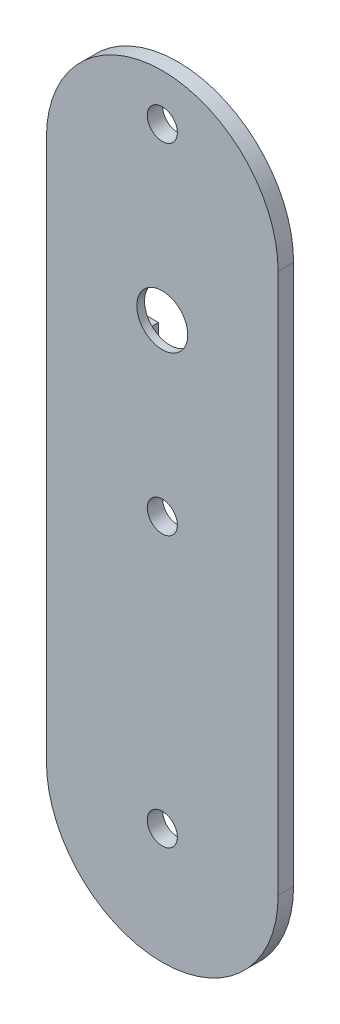
from build123d import *

# Parameters (mm, degrees)
BOSS_EXTRU_1_DEPTH      = 2
D_GAGEMENT_M3_51_D      = 3.9
ENL_V_MAT_EXTRU_3_DEPTH = 1
D_GAGEMENT_M3_52_D      = 3.9
D_GAGEMENT_M61_D        = 6.6


with BuildPart() as part:
    # Esquisse1 → Boss.-Extru.1 (new body)
    with BuildSketch(Plane.XY):
        with BuildLine():
            ThreePointArc((30, 0), (15, -15), (0, 0))
            Line((0, 0), (0, 70))
            ThreePointArc((0, 70), (15, 85), (30, 70))
            Line((30, 70), (30, 0))
        make_face()
    extrude(amount=BOSS_EXTRU_1_DEPTH)

    # Dégagement M3.51 (through all)
    with Locations(Plane(origin=(0, 0, 0), x_dir=(-1, 0, 0), z_dir=(0, 0, -1))):
        with Locations((-15, 79), (-15, 35)):
            Hole(D_GAGEMENT_M3_51_D / 2)

    # Esquisse5 → Enlèv. mat.-Extru.3 (cut)
    with BuildSketch(Plane(origin=(0, 0, 0), x_dir=(-1, 0, 0), z_dir=(0, 0, -1))):
        Polygon((-12.5, 54.5), (-2.5, 54.5), (-2.5, 59.5), (-12.5, 59.5), (-12.5, 69.5), (-17.5, 69.5), (-17.5, 59.5), (-27.5, 59.5), (-27.5, 54.5), (-17.5, 54.5), (-17.5, 44.5), (-12.5, 44.5), align=None)
    extrude(amount=-ENL_V_MAT_EXTRU_3_DEPTH, mode=Mode.SUBTRACT)

    # Dégagement M3.52 (through all)
    with Locations(Plane(origin=(0, 0, 0), x_dir=(-1, 0, 0), z_dir=(0, 0, -1))):
        with Locations((-15, 0)):
            Hole(D_GAGEMENT_M3_52_D / 2)

    # Dégagement M61 (through all)
    with Locations(Plane(origin=(0, 0, 0), x_dir=(-1, 0, 0), z_dir=(0, 0, -1))):
        with Locations((-15, 57)):
            Hole(D_GAGEMENT_M61_D / 2)


solid = part.part
